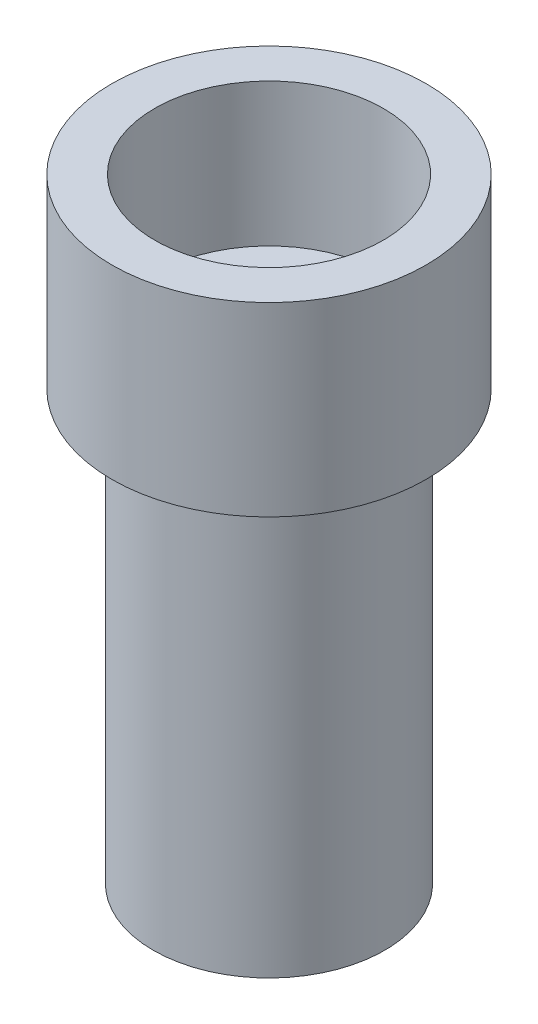
from build123d import *


with BuildPart() as part:
    # Esboço1 → Revolução1 (revolve)
    with BuildSketch(Plane.XY):
        Polygon((4, 21.5), (5.5, 21.5), (5.5, 15), (4.05, 15), (4.05, 0), (0, 0), (0, 16.5), (4, 16.5), align=None)
    revolve(axis=Axis((0, 0, 0), (0, 1, 0)))


solid = part.part
